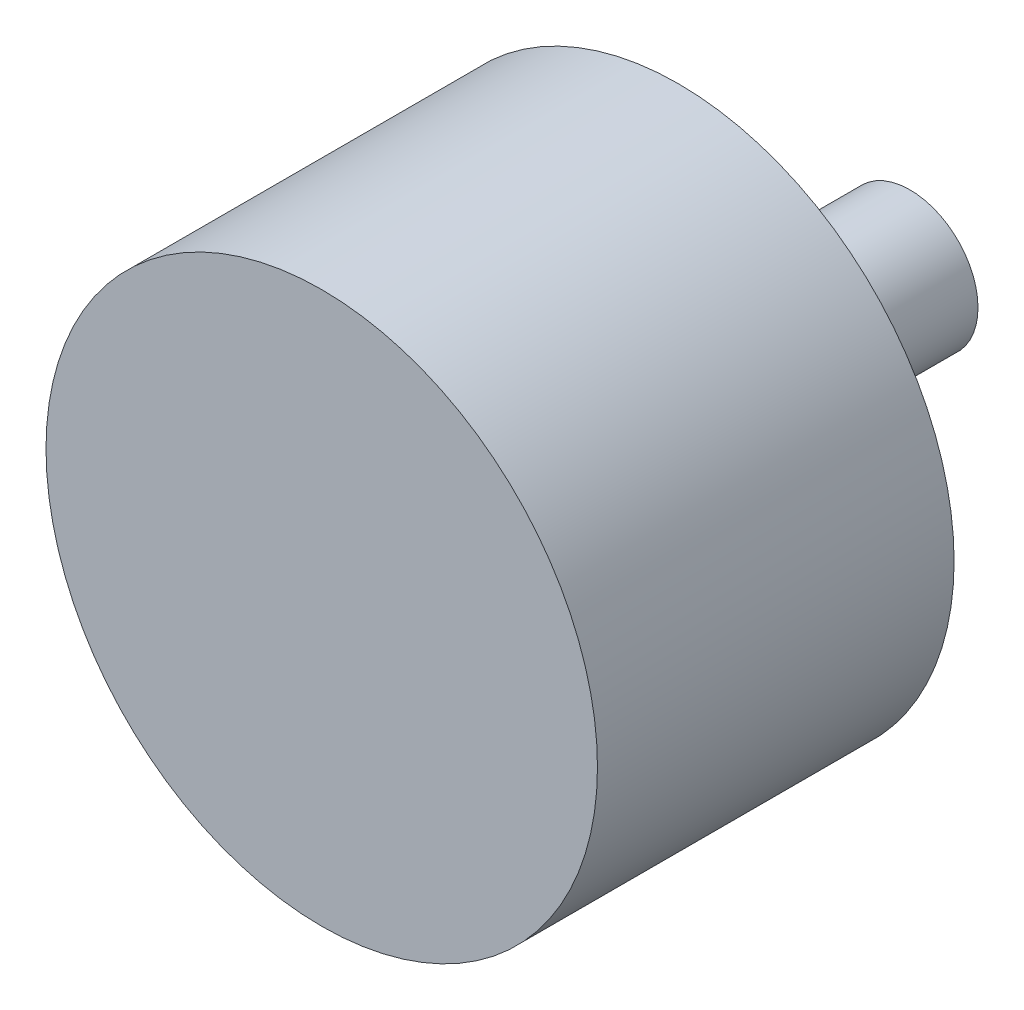
from build123d import *


with BuildPart() as part:
    # Sketch1 → Revolve1 (revolve)
    with BuildSketch(Plane(origin=(0, 0, 0), x_dir=(0, 0, -1), z_dir=(1, 0, 0))):
        Polygon((0, 0), (0, 19.05), (24.638, 19.05), (24.638, 5.461), (30.48, 5.461), (30.48, 4.699), (40.64, 4.699), (40.64, 0), align=None)
    revolve(axis=Axis((0, 0, 0), (0, 0, -1)))


solid = part.part
